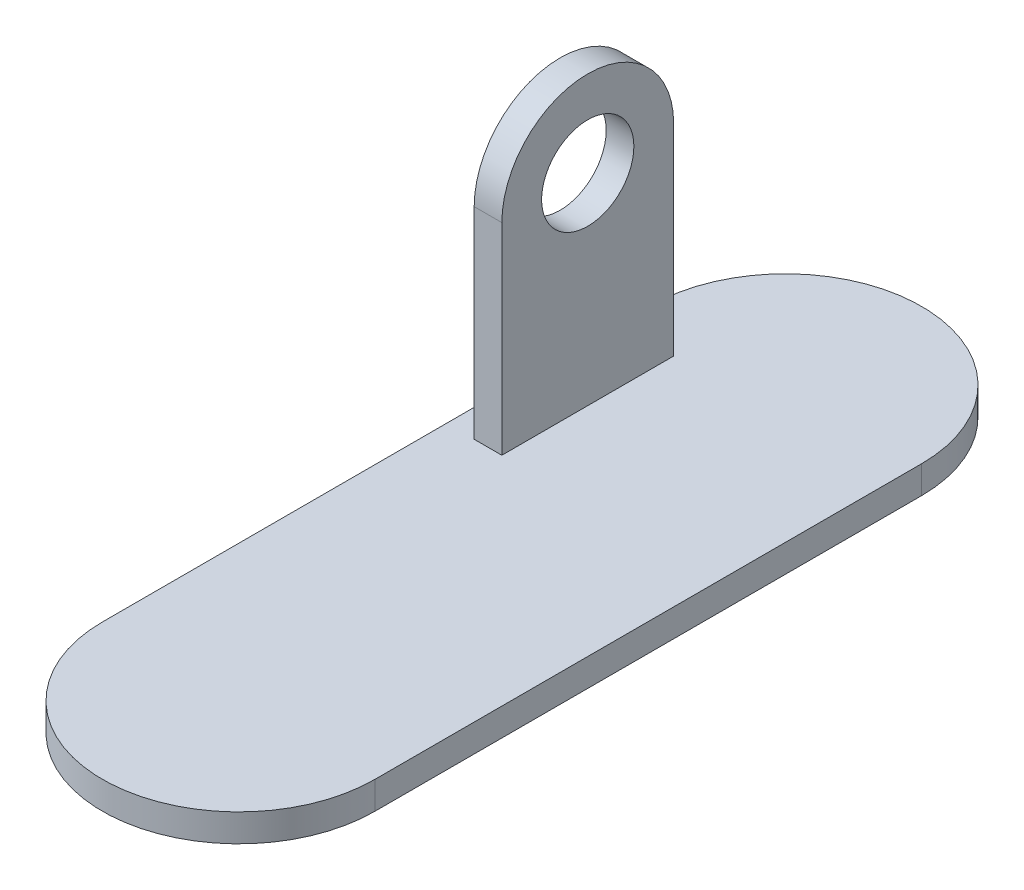
from build123d import *

# Parameters (mm, degrees)
BOSS_EXTRUDE1_DEPTH = 9
SKETCH2_W           = 9
SKETCH2_H           = 55.88
BOSS_EXTRUDE2_DEPTH = 65.53
SKETCH3_R           = 27.94
BOSS_EXTRUDE3_DEPTH = 9
SKETCH4_R           = 15
CUT_EXTRUDE1_DEPTH  = 19


with BuildPart() as part:
    # Sketch1 → Boss-Extrude1 (new body)
    with BuildSketch(Plane(origin=(0, 0, 0), x_dir=(1, 0, 0), z_dir=(0, 1, 0))):
        with BuildLine():
            Line((44.323, 88.9), (44.323, -88.9))
            ThreePointArc((44.323, -88.9), (0, -133.223), (-44.323, -88.9))
            Line((-44.323, -88.9), (-44.323, 88.9))
            ThreePointArc((-44.323, 88.9), (0, 133.223), (44.323, 88.9))
        make_face()
    extrude(amount=BOSS_EXTRUDE1_DEPTH)

    # Sketch2 → Boss-Extrude2 (add)
    with BuildSketch(Plane(origin=(0, 9, 0), x_dir=(1, 0, 0), z_dir=(0, 1, 0))):
        with Locations((-30.823, 50.96)):
            Rectangle(SKETCH2_W, SKETCH2_H)
    extrude(amount=BOSS_EXTRUDE2_DEPTH)

    # Sketch3 → Boss-Extrude3 (add)
    with BuildSketch(Plane(origin=(-26.323, 0, 0), x_dir=(0, 0, -1), z_dir=(1, 0, 0))):
        with Locations((50.96, 74.53)):
            Circle(SKETCH3_R)
    extrude(amount=-BOSS_EXTRUDE3_DEPTH)

    # Sketch4 → Cut-Extrude1 (cut, through all)
    with BuildSketch(Plane(origin=(-26.323, 0, 0), x_dir=(0, 0, -1), z_dir=(1, 0, 0))):
        with Locations((50.96, 74.53)):
            Circle(SKETCH4_R)
    extrude(amount=-CUT_EXTRUDE1_DEPTH, mode=Mode.SUBTRACT)


solid = part.part
